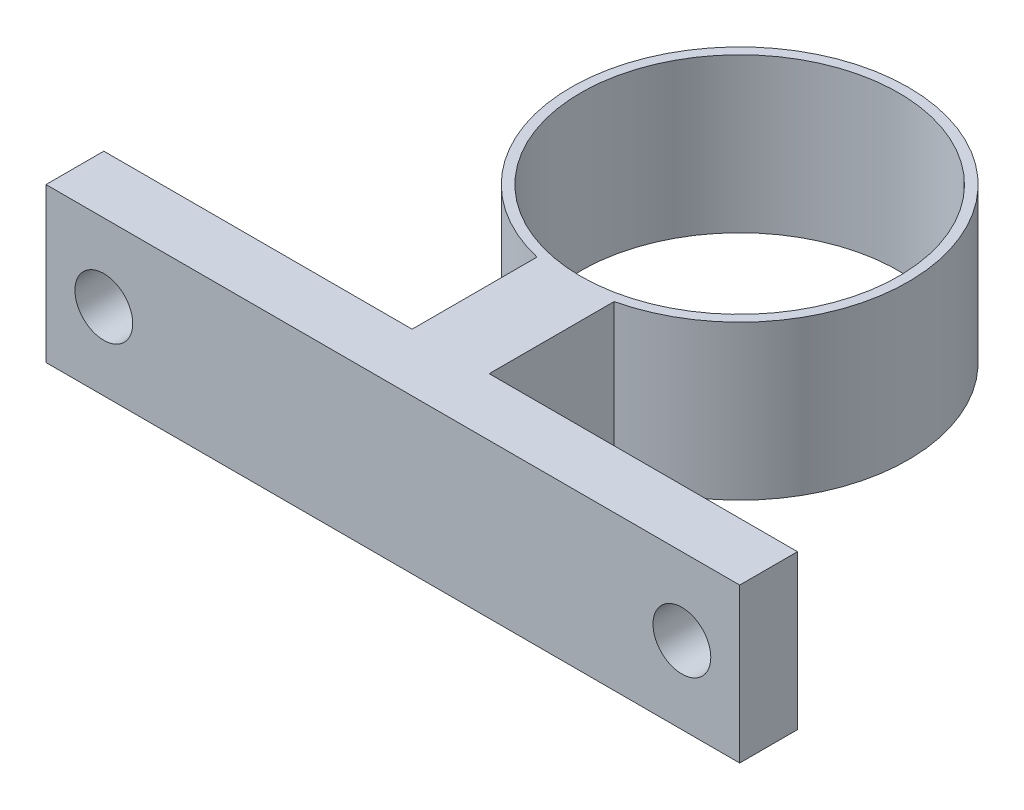
from build123d import *

# Parameters (mm, degrees)
SKETCH_1_R          = 8.75
SKETCH_1_R_2        = 8.25
EXTRUDE_2_DEPTH     = 10
SKETCH_2_R          = 8.25
SKETCH_2_R_2        = 2
EXTRUDE_3_DEPTH     = 4
EXTRUDE_4_DEPTH     = 8
SKETCH_5_W          = 3
SKETCH_5_H          = 8
EXTRUDE_5_DEPTH     = 3
SKETCH_6_W          = 3
SKETCH_6_H          = 8
EXTRUDE_6_DEPTH     = 3
SKETCH_7_R          = 1.5
CUT_EXTRUDE_1_DEPTH = 3
FILLET_1_R          = 5
FILLET_3_R          = 2
SKETCH_8_R          = 8.75
SKETCH_8_R_2        = 8.25
EXTRUDE_7_DEPTH     = 8
SKETCH_9_R          = 8.25
SKETCH_9_R_2        = 6
EXTRUDE_8_DEPTH     = 2
EXTRUDE_9_DEPTH     = 8
SKETCH_11_R         = 1.5
CUT_EXTRUDE_2_DEPTH = 8
CUT_EXTRUDE_3_DEPTH = 8
CUT_EXTRUDE_4_DEPTH = 8
SKETCH_14_R         = 8.75
SKETCH_14_R_2       = 8.25
EXTRUDE_10_DEPTH    = 8
EXTRUDE_11_DEPTH    = 8
SKETCH_16_R         = 1.5
CUT_EXTRUDE_5_DEPTH = 8
CUT_EXTRUDE_6_DEPTH = 10


with BuildPart() as part:
    # 草图1 → 凸台-拉伸2 (new body)
    with BuildSketch(Plane(origin=(0, 0, 0), x_dir=(1, 0, 0), z_dir=(0, 1, 0))):
        Circle(SKETCH_1_R)
        Circle(SKETCH_1_R_2, mode=Mode.SUBTRACT)
    extrude(amount=EXTRUDE_2_DEPTH)

    # 草图2 → 凸台-拉伸3 (add)
    with BuildSketch(Plane(origin=(0, 0, 0), x_dir=(1, 0, 0), z_dir=(0, 1, 0))):
        Circle(SKETCH_2_R)
        Circle(SKETCH_2_R_2, mode=Mode.SUBTRACT)
    extrude(amount=EXTRUDE_3_DEPTH)

    # 草图3 → 凸台-拉伸4 (add)
    with BuildSketch(Plane(origin=(0, 0, 0), x_dir=(1, 0, 0), z_dir=(0, 1, 0))):
        Polygon((-2, 8.518362519), (2, 8.518362519), (2, 15), (15, 15), (15, 18), (2, 18), (-2, 18), (-15, 18), (-15, 15), (-2, 15), align=None)
    extrude(amount=EXTRUDE_4_DEPTH)

    # 草图5 → 凸台-拉伸5 (add)
    with BuildSketch(Plane(origin=(15, 0, 0), x_dir=(0, 0, -1), z_dir=(1, 0, 0))):
        with Locations((16.5, 4)):
            Rectangle(SKETCH_5_W, SKETCH_5_H)
    extrude(amount=EXTRUDE_5_DEPTH)

    # 草图6 → 凸台-拉伸6 (add)
    with BuildSketch(Plane.ZY.offset(15)):
        with Locations((-16.5, 4)):
            Rectangle(SKETCH_6_W, SKETCH_6_H)
    extrude(amount=EXTRUDE_6_DEPTH)

    # 草图7 → 切除-拉伸1 (cut)
    with BuildSketch(Plane(origin=(0, 0, -18), x_dir=(-1, 0, 0), z_dir=(0, 0, -1))):
        with Locations((-15, 3.754021035)):
            Circle(SKETCH_7_R)
    cut_extrude_1 = extrude(amount=-CUT_EXTRUDE_1_DEPTH, mode=Mode.SUBTRACT)

    # 镜向1: 切除-拉伸1 across plane
    add(cut_extrude_1.mirror(Plane(origin=(0, 0, 0), x_dir=(0, 0, 1), z_dir=(1, 0, 0))), mode=Mode.SUBTRACT)

    # 圆角1
    fillet_1_edges = [part.edges().sort_by_distance(p)[0] for p in [
        (-2, 4, -8.518362519),
        (2, 4, -8.518362519),
    ]]
    fillet(fillet_1_edges, radius=FILLET_1_R)

    # 圆角3
    fillet_3_edges = [part.edges().sort_by_distance(p)[0] for p in [
        (-2, 4, -15),
        (2, 4, -15),
    ]]
    fillet(fillet_3_edges, radius=FILLET_3_R)


with BuildPart() as body_2:
    # 草图8 → 凸台-拉伸7 (new body)
    with BuildSketch(Plane(origin=(0, 0, 0), x_dir=(1, 0, 0), z_dir=(0, 1, 0))):
        with Locations((27.184954533, 0)):
            Circle(SKETCH_8_R)
        with Locations((27.184954533, 0)):
            Circle(SKETCH_8_R_2, mode=Mode.SUBTRACT)
    extrude(amount=EXTRUDE_7_DEPTH)

    # 草图9 → 凸台-拉伸8 (add)
    with BuildSketch(Plane.XZ):
        with Locations((27.184954533, 0)):
            Circle(SKETCH_9_R)
        with Locations((27.184954533, 0)):
            Circle(SKETCH_9_R_2, mode=Mode.SUBTRACT)
    extrude(amount=-EXTRUDE_8_DEPTH)

    # 草图10 → 凸台-拉伸9 (add)
    with BuildSketch(Plane(origin=(0, 0, 0), x_dir=(1, 0, 0), z_dir=(0, 1, 0))):
        Polygon((27.184954533, -18), (45.184954533, -18), (45.184954533, -14.663867829), (29.184954533, -14.663867829), (29.184954533, -8.518362519), (25.184954533, -8.518362519), (25.184954533, -14.663867829), (9.184954533, -14.663867829), (9.184954533, -18), align=None)
    extrude(amount=EXTRUDE_9_DEPTH)

    # 草图11 → 切除-拉伸2 (cut)
    with BuildSketch(Plane.XY.offset(18)):
        with Locations((12.184954533, 4)):
            Circle(SKETCH_11_R)
        with Locations((42.184954533, 4)):
            Circle(SKETCH_11_R)
    extrude(amount=-CUT_EXTRUDE_2_DEPTH, mode=Mode.SUBTRACT)

    # 草图12 → 切除-拉伸3 (cut)
    with BuildSketch(Plane.XY.offset(18)):
        with BuildLine():
            Line((10.684954533, 4), (10.684954533, 5))
            ThreePointArc((10.684954533, 5), (12.184954533, 6.5), (13.684954533, 5))
            Line((13.684954533, 5), (13.684954533, 4))
            Line((13.684954533, 4), (13.684954533, 3))
            ThreePointArc((13.684954533, 3), (12.184954533, 1.5), (10.684954533, 3))
            Line((10.684954533, 3), (10.684954533, 4))
        make_face()
    extrude(amount=-CUT_EXTRUDE_3_DEPTH, mode=Mode.SUBTRACT)

    # 草图13 → 切除-拉伸4 (cut)
    with BuildSketch(Plane.XY.offset(18)):
        with BuildLine():
            Line((40.684954533, 4), (40.684954533, 5))
            ThreePointArc((40.684954533, 5), (42.184954533, 6.5), (43.684954533, 5))
            Line((43.684954533, 5), (43.684954533, 4))
            Line((43.684954533, 4), (43.684954533, 3))
            ThreePointArc((43.684954533, 3), (42.184954533, 1.5), (40.684954533, 3))
            Line((40.684954533, 3), (40.684954533, 4))
        make_face()
    extrude(amount=-CUT_EXTRUDE_4_DEPTH, mode=Mode.SUBTRACT)


with BuildPart() as body_3:
    # 草图14 → 凸台-拉伸10 (new body)
    with BuildSketch(Plane(origin=(0, 0, 0), x_dir=(1, 0, 0), z_dir=(0, 1, 0))):
        with Locations((-35.091635024, 0)):
            Circle(SKETCH_14_R)
        with Locations((-35.091635024, 0)):
            Circle(SKETCH_14_R_2, mode=Mode.SUBTRACT)
    extrude(amount=EXTRUDE_10_DEPTH)

    # 草图15 → 凸台-拉伸11 (add)
    with BuildSketch(Plane(origin=(0, 0, 0), x_dir=(1, 0, 0), z_dir=(0, 1, 0))):
        Polygon((-37.091635024, -15), (-37.091635024, -8.518362519), (-33.091635024, -8.518362519), (-33.091635024, -15), (-17.091635024, -15), (-17.091635024, -18), (-53.091635024, -18), (-53.091635024, -15), align=None)
    extrude(amount=EXTRUDE_11_DEPTH)

    # 草图16 → 切除-拉伸5 (cut)
    with BuildSketch(Plane.XY.offset(18)):
        with Locations((-50.091635024, 4)):
            Circle(SKETCH_16_R)
        with Locations((-20.091635024, 4)):
            Circle(SKETCH_16_R)
    extrude(amount=-CUT_EXTRUDE_5_DEPTH, mode=Mode.SUBTRACT)


with BuildPart() as cut_extrude_6_tool:
    # 草图17 → 切除-拉伸6 (new body)
    with BuildSketch(Plane(origin=(0, 0, 0), x_dir=(1, 0, 0), z_dir=(0, 1, 0))):
        Polygon((-22.814109192, 34.802391794), (-16.193349778, -3.968895549), (-7.026713263, -18.825168522), (52.714469541, -30.836623265), (64.093742456, -10), (34.287483401, 32.08598291), align=None)
    extrude(amount=CUT_EXTRUDE_6_DEPTH)


with BuildPart() as part_1:
    add(part.part)

    # 切除-拉伸6: cut by cut_extrude_6_tool
    add(cut_extrude_6_tool.part, mode=Mode.SUBTRACT)


with BuildPart() as body_2_1:
    add(body_2.part)

    # 切除-拉伸6: cut by cut_extrude_6_tool
    add(cut_extrude_6_tool.part, mode=Mode.SUBTRACT)


solid = body_3.part
